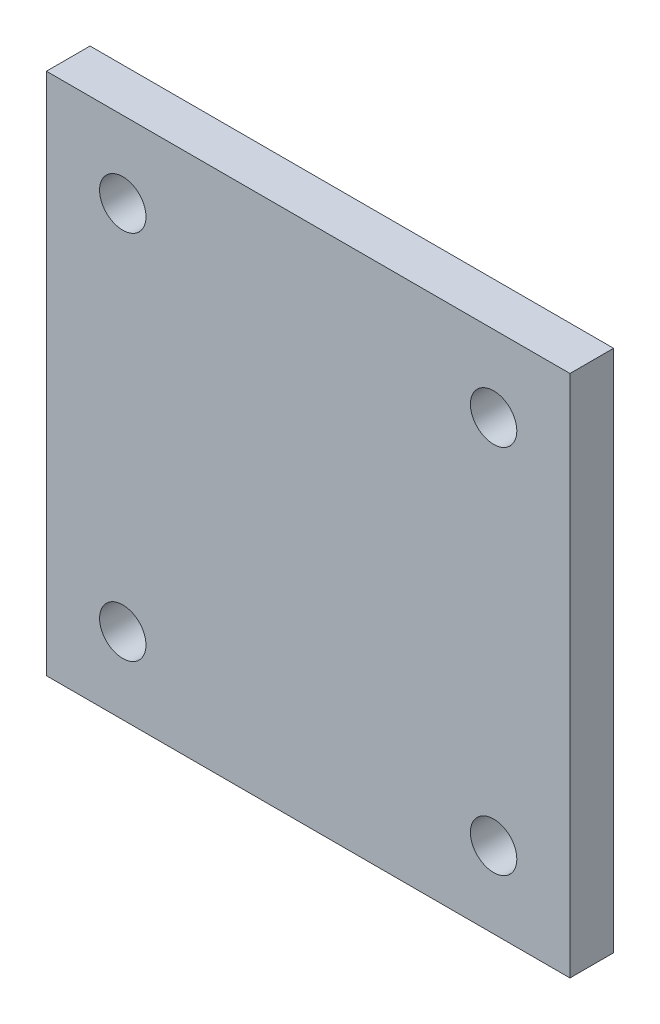
from build123d import *

# Parameters (mm, degrees)
SKETCH1_W               = 76.2
SKETCH1_H               = 76.2
EXTRUDE1_DEPTH          = 6.35
F_1_4_CLEARANCE_HOLE1_D = 6.7564


with BuildPart() as part:
    # Sketch1 → Extrude1 (new body)
    with BuildSketch(Plane.XY):
        Rectangle(SKETCH1_W, SKETCH1_H)
    extrude(amount=EXTRUDE1_DEPTH)

    # 1/4 Clearance Hole1 (through all)
    with Locations(Plane.XY.offset(6.35)):
        with Locations((-26.9875, 26.9875), (26.9875, 26.9875), (26.9875, -26.9875), (-26.9875, -26.9875)):
            Hole(F_1_4_CLEARANCE_HOLE1_D / 2)


solid = part.part
